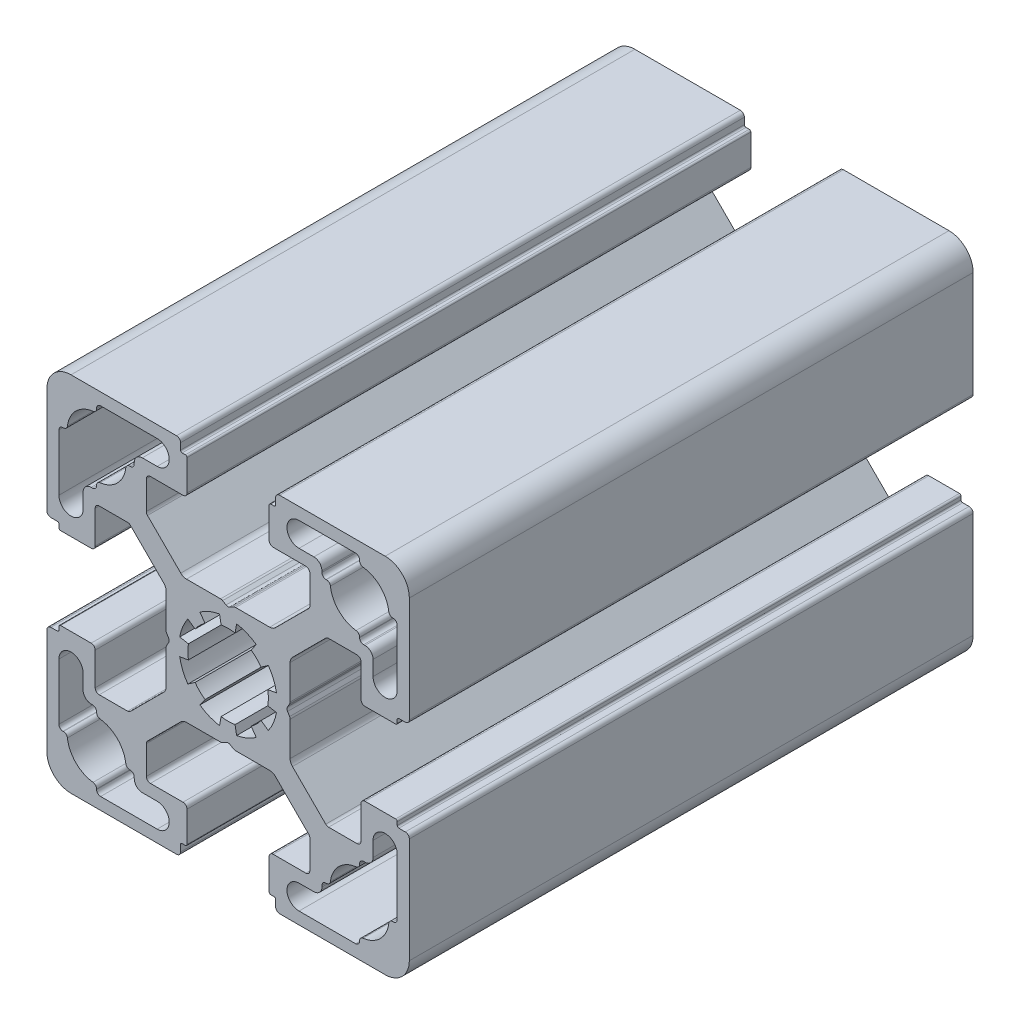
from build123d import *

# Parameters (mm, degrees)
EXTRUDE_4_DEPTH = 70


with BuildPart() as part:
    # Эскиз1 → Бобышка-Вытянуть4 (new body)
    with BuildSketch(Plane.XY):
        with BuildLine():
            Line((-7.700480433, 0.929088242), (-7.700480433, 5.164946528))
            ThreePointArc((-7.700480433, 5.164946528), (-7.776600901, 5.54762996), (-7.993373652, 5.872053309))
            Line((-7.993373652, 5.872053309), (-10.240131415, 8.118811071))
            Line((-10.240131415, 8.118811071), (-12.124873734, 10.003553391))
            ThreePointArc((-12.124873734, 10.003553391), (-12.287085409, 10.111939766), (-12.478427125, 10.15))
            Line((-12.478427125, 10.15), (-16, 10.15))
            ThreePointArc((-16, 10.15), (-16.353553391, 10.003553391), (-16.5, 9.65))
            Line((-16.5, 9.65), (-16.5, 5.6))
            ThreePointArc((-16.5, 5.6), (-16.646446609, 5.246446609), (-17, 5.1))
            Line((-17, 5.1), (-20.8, 5.1))
            ThreePointArc((-20.8, 5.1), (-20.941421356, 5.158578644), (-21, 5.3))
            Line((-21, 5.3), (-21, 5.7))
            ThreePointArc((-21, 5.7), (-21.058578644, 5.841421356), (-21.2, 5.9))
            Line((-21.2, 5.9), (-22, 5.9))
            ThreePointArc((-22, 5.9), (-22.353553391, 6.046446609), (-22.5, 6.4))
            Line((-22.5, 6.4), (-22.5, 19.5))
            ThreePointArc((-22.5, 19.5), (-21.621320344, 21.621320344), (-19.5, 22.5))
            Line((-19.5, 22.5), (-6.4, 22.5))
            ThreePointArc((-6.4, 22.5), (-6.046446609, 22.353553391), (-5.9, 22))
            Line((-5.9, 22), (-5.9, 21.2))
            ThreePointArc((-5.9, 21.2), (-5.841421356, 21.058578644), (-5.7, 21))
            Line((-5.7, 21), (-5.3, 21))
            ThreePointArc((-5.3, 21), (-5.158578644, 20.941421356), (-5.1, 20.8))
            Line((-5.1, 20.8), (-5.1, 17))
            ThreePointArc((-5.1, 17), (-5.246446609, 16.646446609), (-5.6, 16.5))
            Line((-5.6, 16.5), (-9.65, 16.5))
            ThreePointArc((-9.65, 16.5), (-10.003553391, 16.353553391), (-10.15, 16))
            Line((-10.15, 16), (-10.15, 12.478427125))
            ThreePointArc((-10.15, 12.478427125), (-10.111939766, 12.287085409), (-10.003553391, 12.124873734))
            Line((-10.003553391, 12.124873734), (-8.118811071, 10.240131415))
            Line((-8.118811071, 10.240131415), (-5.872053309, 7.993373652))
            ThreePointArc((-5.872053309, 7.993373652), (-5.54762996, 7.776600901), (-5.164946528, 7.700480433))
            Line((-5.164946528, 7.700480433), (-0.929088242, 7.700480433))
            ThreePointArc((-0.929088242, 7.700480433), (-0.799678719, 7.683443347), (-0.679088242, 7.633493135))
            Line((-0.679088242, 7.633493135), (-0.25, 7.385758924))
            ThreePointArc((-0.25, 7.385758924), (0, 7.318771625), (0.25, 7.385758924))
            Line((0.25, 7.385758924), (0.679088242, 7.633493135))
            ThreePointArc((0.679088242, 7.633493135), (0.799678719, 7.683443347), (0.929088242, 7.700480433))
            Line((0.929088242, 7.700480433), (5.164946528, 7.700480433))
            ThreePointArc((5.164946528, 7.700480433), (5.54762996, 7.776600901), (5.872053309, 7.993373652))
            Line((5.872053309, 7.993373652), (8.118811071, 10.240131415))
            Line((8.118811071, 10.240131415), (10.003553391, 12.124873734))
            ThreePointArc((10.003553391, 12.124873734), (10.111939766, 12.287085409), (10.15, 12.478427125))
            Line((10.15, 12.478427125), (10.15, 16))
            ThreePointArc((10.15, 16), (10.003553391, 16.353553391), (9.65, 16.5))
            Line((9.65, 16.5), (5.6, 16.5))
            ThreePointArc((5.6, 16.5), (5.246446609, 16.646446609), (5.1, 17))
            Line((5.1, 17), (5.1, 20.8))
            ThreePointArc((5.1, 20.8), (5.158578644, 20.941421356), (5.3, 21))
            Line((5.3, 21), (5.7, 21))
            ThreePointArc((5.7, 21), (5.841421356, 21.058578644), (5.9, 21.2))
            Line((5.9, 21.2), (5.9, 22))
            ThreePointArc((5.9, 22), (6.046446609, 22.353553391), (6.4, 22.5))
            Line((6.4, 22.5), (19.5, 22.5))
            ThreePointArc((19.5, 22.5), (21.621320344, 21.621320344), (22.5, 19.5))
            Line((22.5, 19.5), (22.5, 6.4))
            ThreePointArc((22.5, 6.4), (22.353553391, 6.046446609), (22, 5.9))
            Line((22, 5.9), (21.2, 5.9))
            ThreePointArc((21.2, 5.9), (21.058578644, 5.841421356), (21, 5.7))
            Line((21, 5.7), (21, 5.3))
            ThreePointArc((21, 5.3), (20.941421356, 5.158578644), (20.8, 5.1))
            Line((20.8, 5.1), (17, 5.1))
            ThreePointArc((17, 5.1), (16.646446609, 5.246446609), (16.5, 5.6))
            Line((16.5, 5.6), (16.5, 9.65))
            ThreePointArc((16.5, 9.65), (16.353553391, 10.003553391), (16, 10.15))
            Line((16, 10.15), (12.478427125, 10.15))
            ThreePointArc((12.478427125, 10.15), (12.287085409, 10.111939766), (12.124873734, 10.003553391))
            Line((12.124873734, 10.003553391), (10.240131415, 8.118811071))
            Line((10.240131415, 8.118811071), (7.993373652, 5.872053309))
            ThreePointArc((7.993373652, 5.872053309), (7.776600901, 5.54762996), (7.700480433, 5.164946528))
            Line((7.700480433, 5.164946528), (7.700480433, 0.929088242))
            ThreePointArc((7.700480433, 0.929088242), (7.683443347, 0.799678719), (7.633493135, 0.679088242))
            Line((7.633493135, 0.679088242), (7.385758924, 0.25))
            ThreePointArc((7.385758924, 0.25), (7.318771625, 0), (7.385758924, -0.25))
            Line((7.385758924, -0.25), (7.633493135, -0.679088242))
            ThreePointArc((7.633493135, -0.679088242), (7.683443347, -0.799678719), (7.700480433, -0.929088242))
            Line((7.700480433, -0.929088242), (7.700480433, -5.164946528))
            ThreePointArc((7.700480433, -5.164946528), (7.776600901, -5.54762996), (7.993373652, -5.872053309))
            Line((7.993373652, -5.872053309), (10.240131415, -8.118811071))
            Line((10.240131415, -8.118811071), (12.124873734, -10.003553391))
            ThreePointArc((12.124873734, -10.003553391), (12.287085409, -10.111939766), (12.478427125, -10.15))
            Line((12.478427125, -10.15), (16, -10.15))
            ThreePointArc((16, -10.15), (16.353553391, -10.003553391), (16.5, -9.65))
            Line((16.5, -9.65), (16.5, -5.6))
            ThreePointArc((16.5, -5.6), (16.646446609, -5.246446609), (17, -5.1))
            Line((17, -5.1), (20.8, -5.1))
            ThreePointArc((20.8, -5.1), (20.941421356, -5.158578644), (21, -5.3))
            Line((21, -5.3), (21, -5.7))
            ThreePointArc((21, -5.7), (21.058578644, -5.841421356), (21.2, -5.9))
            Line((21.2, -5.9), (22, -5.9))
            ThreePointArc((22, -5.9), (22.353553391, -6.046446609), (22.5, -6.4))
            Line((22.5, -6.4), (22.5, -19.5))
            ThreePointArc((22.5, -19.5), (21.621320344, -21.621320344), (19.5, -22.5))
            Line((19.5, -22.5), (6.4, -22.5))
            ThreePointArc((6.4, -22.5), (6.046446609, -22.353553391), (5.9, -22))
            Line((5.9, -22), (5.9, -21.2))
            ThreePointArc((5.9, -21.2), (5.841421356, -21.058578644), (5.7, -21))
            Line((5.7, -21), (5.3, -21))
            ThreePointArc((5.3, -21), (5.158578644, -20.941421356), (5.1, -20.8))
            Line((5.1, -20.8), (5.1, -17))
            ThreePointArc((5.1, -17), (5.246446609, -16.646446609), (5.6, -16.5))
            Line((5.6, -16.5), (9.65, -16.5))
            ThreePointArc((9.65, -16.5), (10.003553391, -16.353553391), (10.15, -16))
            Line((10.15, -16), (10.15, -12.478427125))
            ThreePointArc((10.15, -12.478427125), (10.111939766, -12.287085409), (10.003553391, -12.124873734))
            Line((10.003553391, -12.124873734), (8.118811071, -10.240131415))
            Line((8.118811071, -10.240131415), (5.872053309, -7.993373652))
            ThreePointArc((5.872053309, -7.993373652), (5.54762996, -7.776600901), (5.164946528, -7.700480433))
            Line((5.164946528, -7.700480433), (0.929088242, -7.700480433))
            ThreePointArc((0.929088242, -7.700480433), (0.799678719, -7.683443347), (0.679088242, -7.633493135))
            Line((0.679088242, -7.633493135), (0.25, -7.385758924))
            ThreePointArc((0.25, -7.385758924), (0, -7.318771625), (-0.25, -7.385758924))
            Line((-0.25, -7.385758924), (-0.679088242, -7.633493135))
            ThreePointArc((-0.679088242, -7.633493135), (-0.799678719, -7.683443347), (-0.929088242, -7.700480433))
            Line((-0.929088242, -7.700480433), (-5.164946528, -7.700480433))
            ThreePointArc((-5.164946528, -7.700480433), (-5.54762996, -7.776600901), (-5.872053309, -7.993373652))
            Line((-5.872053309, -7.993373652), (-8.118811071, -10.240131415))
            Line((-8.118811071, -10.240131415), (-10.003553391, -12.124873734))
            ThreePointArc((-10.003553391, -12.124873734), (-10.111939766, -12.287085409), (-10.15, -12.478427125))
            Line((-10.15, -12.478427125), (-10.15, -16))
            ThreePointArc((-10.15, -16), (-10.003553391, -16.353553391), (-9.65, -16.5))
            Line((-9.65, -16.5), (-5.6, -16.5))
            ThreePointArc((-5.6, -16.5), (-5.246446609, -16.646446609), (-5.1, -17))
            Line((-5.1, -17), (-5.1, -20.8))
            ThreePointArc((-5.1, -20.8), (-5.158578644, -20.941421356), (-5.3, -21))
            Line((-5.3, -21), (-5.7, -21))
            ThreePointArc((-5.7, -21), (-5.841421356, -21.058578644), (-5.9, -21.2))
            Line((-5.9, -21.2), (-5.9, -22))
            ThreePointArc((-5.9, -22), (-6.046446609, -22.353553391), (-6.4, -22.5))
            Line((-6.4, -22.5), (-19.5, -22.5))
            ThreePointArc((-19.5, -22.5), (-21.621320344, -21.621320344), (-22.5, -19.5))
            Line((-22.5, -19.5), (-22.5, -6.4))
            ThreePointArc((-22.5, -6.4), (-22.353553391, -6.046446609), (-22, -5.9))
            Line((-22, -5.9), (-21.2, -5.9))
            ThreePointArc((-21.2, -5.9), (-21.058578644, -5.841421356), (-21, -5.7))
            Line((-21, -5.7), (-21, -5.3))
            ThreePointArc((-21, -5.3), (-20.941421356, -5.158578644), (-20.8, -5.1))
            Line((-20.8, -5.1), (-17, -5.1))
            ThreePointArc((-17, -5.1), (-16.646446609, -5.246446609), (-16.5, -5.6))
            Line((-16.5, -5.6), (-16.5, -9.65))
            ThreePointArc((-16.5, -9.65), (-16.353553391, -10.003553391), (-16, -10.15))
            Line((-16, -10.15), (-12.478427125, -10.15))
            ThreePointArc((-12.478427125, -10.15), (-12.287085409, -10.111939766), (-12.124873734, -10.003553391))
            Line((-12.124873734, -10.003553391), (-10.240131415, -8.118811071))
            Line((-10.240131415, -8.118811071), (-7.993373652, -5.872053309))
            ThreePointArc((-7.993373652, -5.872053309), (-7.776600901, -5.54762996), (-7.700480433, -5.164946528))
            Line((-7.700480433, -5.164946528), (-7.700480433, -0.929088242))
            ThreePointArc((-7.700480433, -0.929088242), (-7.683443347, -0.799678719), (-7.633493135, -0.679088242))
            Line((-7.633493135, -0.679088242), (-7.385758924, -0.25))
            ThreePointArc((-7.385758924, -0.25), (-7.318771625, 0), (-7.385758924, 0.25))
            Line((-7.385758924, 0.25), (-7.633493135, 0.679088242))
            ThreePointArc((-7.633493135, 0.679088242), (-7.683443347, 0.799678719), (-7.700480433, 0.929088242))
        make_face()
        with BuildLine():
            Line((-21, 15.825), (-21, 8.807951074))
            ThreePointArc((-21, 8.807951074), (-19.5, 7.307951074), (-18, 8.807951074))
            Line((-18, 8.807951074), (-18, 10.65))
            ThreePointArc((-18, 10.65), (-17.707106781, 11.357106781), (-17, 11.65))
            Line((-17, 11.65), (-16.825, 11.65))
            ThreePointArc((-16.825, 11.65), (-16.471446609, 11.796446609), (-16.325, 12.15))
            Line((-16.325, 12.15), (-16.325, 12.205230589))
            ThreePointArc((-16.325, 12.205230589), (-16.19924623, 12.536802239), (-15.885240964, 12.701588349))
            ThreePointArc((-15.885240964, 12.701588349), (-13.744060249, 13.744060249), (-12.701588349, 15.885240964))
            ThreePointArc((-12.701588349, 15.885240964), (-12.536802239, 16.19924623), (-12.205230589, 16.325))
            Line((-12.205230589, 16.325), (-12.15, 16.325))
            ThreePointArc((-12.15, 16.325), (-11.796446609, 16.471446609), (-11.65, 16.825))
            Line((-11.65, 16.825), (-11.65, 17))
            ThreePointArc((-11.65, 17), (-11.357106781, 17.707106781), (-10.65, 18))
            Line((-10.65, 18), (-8.807951074, 18))
            ThreePointArc((-8.807951074, 18), (-7.307951074, 19.5), (-8.807951074, 21))
            Line((-8.807951074, 21), (-15.825, 21))
            ThreePointArc((-15.825, 21), (-16.178553391, 20.853553391), (-16.325, 20.5))
            Line((-16.325, 20.5), (-16.325, 20.444769411))
            ThreePointArc((-16.325, 20.444769411), (-16.45075377, 20.113197761), (-16.764759036, 19.948411651))
            ThreePointArc((-16.764759036, 19.948411651), (-18.905939751, 18.905939751), (-19.948411651, 16.764759036))
            ThreePointArc((-19.948411651, 16.764759036), (-20.113197761, 16.45075377), (-20.444769411, 16.325))
            Line((-20.444769411, 16.325), (-20.5, 16.325))
            ThreePointArc((-20.5, 16.325), (-20.853553391, 16.178553391), (-21, 15.825))
        make_face(mode=Mode.SUBTRACT)
        with BuildLine():
            Line((-15.825, -21), (-8.807951074, -21))
            ThreePointArc((-8.807951074, -21), (-7.307951074, -19.5), (-8.807951074, -18))
            Line((-8.807951074, -18), (-10.65, -18))
            ThreePointArc((-10.65, -18), (-11.357106781, -17.707106781), (-11.65, -17))
            Line((-11.65, -17), (-11.65, -16.825))
            ThreePointArc((-11.65, -16.825), (-11.796446609, -16.471446609), (-12.15, -16.325))
            Line((-12.15, -16.325), (-12.205230589, -16.325))
            ThreePointArc((-12.205230589, -16.325), (-12.536802239, -16.19924623), (-12.701588349, -15.885240964))
            ThreePointArc((-12.701588349, -15.885240964), (-13.744060249, -13.744060249), (-15.885240964, -12.701588349))
            ThreePointArc((-15.885240964, -12.701588349), (-16.19924623, -12.536802239), (-16.325, -12.205230589))
            Line((-16.325, -12.205230589), (-16.325, -12.15))
            ThreePointArc((-16.325, -12.15), (-16.471446609, -11.796446609), (-16.825, -11.65))
            Line((-16.825, -11.65), (-17, -11.65))
            ThreePointArc((-17, -11.65), (-17.707106781, -11.357106781), (-18, -10.65))
            Line((-18, -10.65), (-18, -8.807951074))
            ThreePointArc((-18, -8.807951074), (-19.5, -7.307951074), (-21, -8.807951074))
            Line((-21, -8.807951074), (-21, -15.825))
            ThreePointArc((-21, -15.825), (-20.853553391, -16.178553391), (-20.5, -16.325))
            Line((-20.5, -16.325), (-20.444769411, -16.325))
            ThreePointArc((-20.444769411, -16.325), (-20.113197761, -16.45075377), (-19.948411651, -16.764759036))
            ThreePointArc((-19.948411651, -16.764759036), (-18.905939751, -18.905939751), (-16.764759036, -19.948411651))
            ThreePointArc((-16.764759036, -19.948411651), (-16.45075377, -20.113197761), (-16.325, -20.444769411))
            Line((-16.325, -20.444769411), (-16.325, -20.5))
            ThreePointArc((-16.325, -20.5), (-16.178553391, -20.853553391), (-15.825, -21))
        make_face(mode=Mode.SUBTRACT)
        with BuildLine():
            Line((15.825, 21), (8.807951074, 21))
            ThreePointArc((8.807951074, 21), (7.307951074, 19.5), (8.807951074, 18))
            Line((8.807951074, 18), (10.65, 18))
            ThreePointArc((10.65, 18), (11.357106781, 17.707106781), (11.65, 17))
            Line((11.65, 17), (11.65, 16.825))
            ThreePointArc((11.65, 16.825), (11.796446609, 16.471446609), (12.15, 16.325))
            Line((12.15, 16.325), (12.205230589, 16.325))
            ThreePointArc((12.205230589, 16.325), (12.536802239, 16.19924623), (12.701588349, 15.885240964))
            ThreePointArc((12.701588349, 15.885240964), (13.744060249, 13.744060249), (15.885240964, 12.701588349))
            ThreePointArc((15.885240964, 12.701588349), (16.19924623, 12.536802239), (16.325, 12.205230589))
            Line((16.325, 12.205230589), (16.325, 12.15))
            ThreePointArc((16.325, 12.15), (16.471446609, 11.796446609), (16.825, 11.65))
            Line((16.825, 11.65), (17, 11.65))
            ThreePointArc((17, 11.65), (17.707106781, 11.357106781), (18, 10.65))
            Line((18, 10.65), (18, 8.807951074))
            ThreePointArc((18, 8.807951074), (19.5, 7.307951074), (21, 8.807951074))
            Line((21, 8.807951074), (21, 15.825))
            ThreePointArc((21, 15.825), (20.853553391, 16.178553391), (20.5, 16.325))
            Line((20.5, 16.325), (20.444769411, 16.325))
            ThreePointArc((20.444769411, 16.325), (20.113197761, 16.45075377), (19.948411651, 16.764759036))
            ThreePointArc((19.948411651, 16.764759036), (18.905939751, 18.905939751), (16.764759036, 19.948411651))
            ThreePointArc((16.764759036, 19.948411651), (16.45075377, 20.113197761), (16.325, 20.444769411))
            Line((16.325, 20.444769411), (16.325, 20.5))
            ThreePointArc((16.325, 20.5), (16.178553391, 20.853553391), (15.825, 21))
        make_face(mode=Mode.SUBTRACT)
        with BuildLine():
            Line((-2.867882182, 4.095760221), (-3.498816262, 4.99682747))
            ThreePointArc((-3.498816262, 4.99682747), (-2.334368937, 5.635665148), (-1.059253884, 6.007327293))
            Line((-1.059253884, 6.007327293), (-0.868240888, 4.924038765))
            ThreePointArc((-0.868240888, 4.924038765), (0, 5), (0.868240888, 4.924038765))
            Line((0.868240888, 4.924038765), (1.059253884, 6.007327293))
            ThreePointArc((1.059253884, 6.007327293), (2.334368937, 5.635665148), (3.498816262, 4.99682747))
            Line((3.498816262, 4.99682747), (2.867882182, 4.095760221))
            ThreePointArc((2.867882182, 4.095760221), (3.535533906, 3.535533906), (4.095760221, 2.867882182))
            Line((4.095760221, 2.867882182), (4.99682747, 3.498816262))
            ThreePointArc((4.99682747, 3.498816262), (5.635665148, 2.334368937), (6.007327293, 1.059253884))
            Line((6.007327293, 1.059253884), (4.924038765, 0.868240888))
            ThreePointArc((4.924038765, 0.868240888), (5, 0), (4.924038765, -0.868240888))
            Line((4.924038765, -0.868240888), (6.007327293, -1.059253884))
            ThreePointArc((6.007327293, -1.059253884), (5.635665148, -2.334368937), (4.99682747, -3.498816262))
            Line((4.99682747, -3.498816262), (4.095760221, -2.867882182))
            ThreePointArc((4.095760221, -2.867882182), (3.535533906, -3.535533906), (2.867882182, -4.095760221))
            Line((2.867882182, -4.095760221), (3.498816262, -4.99682747))
            ThreePointArc((3.498816262, -4.99682747), (2.334368937, -5.635665148), (1.059253884, -6.007327293))
            Line((1.059253884, -6.007327293), (0.868240888, -4.924038765))
            ThreePointArc((0.868240888, -4.924038765), (0, -5), (-0.868240888, -4.924038765))
            Line((-0.868240888, -4.924038765), (-1.059253884, -6.007327293))
            ThreePointArc((-1.059253884, -6.007327293), (-2.334368937, -5.635665148), (-3.498816262, -4.99682747))
            Line((-3.498816262, -4.99682747), (-2.867882182, -4.095760221))
            ThreePointArc((-2.867882182, -4.095760221), (-3.535533906, -3.535533906), (-4.095760221, -2.867882182))
            Line((-4.095760221, -2.867882182), (-4.99682747, -3.498816262))
            ThreePointArc((-4.99682747, -3.498816262), (-5.635665148, -2.334368937), (-6.007327293, -1.059253884))
            Line((-6.007327293, -1.059253884), (-4.924038765, -0.868240888))
            ThreePointArc((-4.924038765, -0.868240888), (-5, 0), (-4.924038765, 0.868240888))
            Line((-4.924038765, 0.868240888), (-6.007327293, 1.059253884))
            ThreePointArc((-6.007327293, 1.059253884), (-5.635665148, 2.334368937), (-4.99682747, 3.498816262))
            Line((-4.99682747, 3.498816262), (-4.095760221, 2.867882182))
            ThreePointArc((-4.095760221, 2.867882182), (-3.535533906, 3.535533906), (-2.867882182, 4.095760221))
        make_face(mode=Mode.SUBTRACT)
        with BuildLine():
            Line((21, -15.825), (21, -8.807951074))
            ThreePointArc((21, -8.807951074), (19.5, -7.307951074), (18, -8.807951074))
            Line((18, -8.807951074), (18, -10.65))
            ThreePointArc((18, -10.65), (17.707106781, -11.357106781), (17, -11.65))
            Line((17, -11.65), (16.825, -11.65))
            ThreePointArc((16.825, -11.65), (16.471446609, -11.796446609), (16.325, -12.15))
            Line((16.325, -12.15), (16.325, -12.205230589))
            ThreePointArc((16.325, -12.205230589), (16.19924623, -12.536802239), (15.885240964, -12.701588349))
            ThreePointArc((15.885240964, -12.701588349), (13.744060249, -13.744060249), (12.701588349, -15.885240964))
            ThreePointArc((12.701588349, -15.885240964), (12.536802239, -16.19924623), (12.205230589, -16.325))
            Line((12.205230589, -16.325), (12.15, -16.325))
            ThreePointArc((12.15, -16.325), (11.796446609, -16.471446609), (11.65, -16.825))
            Line((11.65, -16.825), (11.65, -17))
            ThreePointArc((11.65, -17), (11.357106781, -17.707106781), (10.65, -18))
            Line((10.65, -18), (8.807951074, -18))
            ThreePointArc((8.807951074, -18), (7.307951074, -19.5), (8.807951074, -21))
            Line((8.807951074, -21), (15.825, -21))
            ThreePointArc((15.825, -21), (16.178553391, -20.853553391), (16.325, -20.5))
            Line((16.325, -20.5), (16.325, -20.444769411))
            ThreePointArc((16.325, -20.444769411), (16.45075377, -20.113197761), (16.764759036, -19.948411651))
            ThreePointArc((16.764759036, -19.948411651), (18.905939751, -18.905939751), (19.948411651, -16.764759036))
            ThreePointArc((19.948411651, -16.764759036), (20.113197761, -16.45075377), (20.444769411, -16.325))
            Line((20.444769411, -16.325), (20.5, -16.325))
            ThreePointArc((20.5, -16.325), (20.853553391, -16.178553391), (21, -15.825))
        make_face(mode=Mode.SUBTRACT)
    extrude(amount=EXTRUDE_4_DEPTH)


solid = part.part
